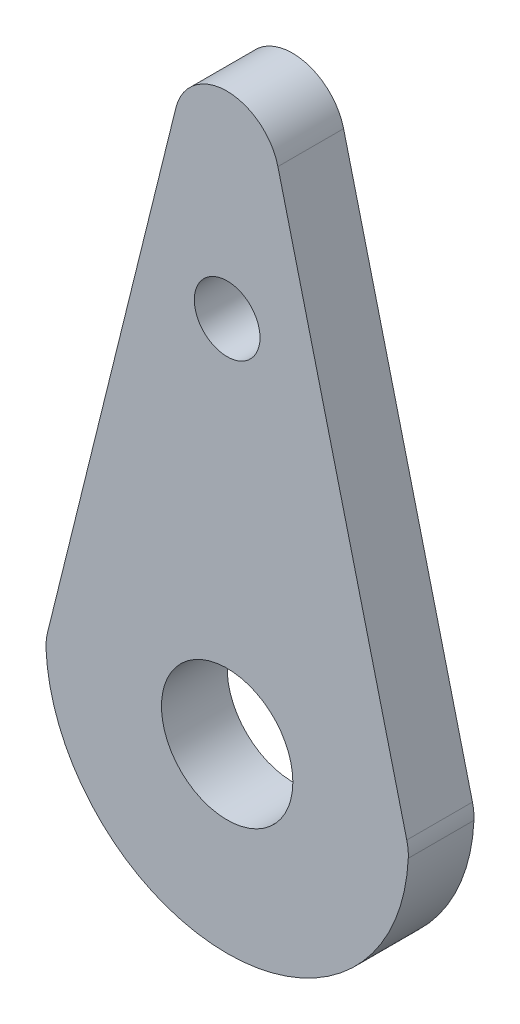
from build123d import *

# Parameters (mm, degrees)
SKETCH1_R                    = 3.175
BOSS_EXTRUDE1_DEPTH          = 3.175
F_1_8_0_125_DIAMETER_HOLE1_D = 3.175


with BuildPart() as part:
    # Sketch1 → Boss-Extrude1 (new body)
    with BuildSketch(Plane.XY):
        with BuildLine():
            Line((-8.682173031, 0.326637814), (-2.477735609, 25.4))
            ThreePointArc((-2.477735609, 25.4), (-0.013242247, 27.329875409), (2.45298258, 25.402213164))
            Line((2.45298258, 25.402213164), (8.681575809, 0.327789055))
            ThreePointArc((8.681575809, 0.327789055), (8.744087205, -0.033833939), (8.753834359, -0.400690665))
            ThreePointArc((8.753834359, -0.400690665), (-0.00074846, -8.762999968), (-8.753902679, -0.399195305))
            ThreePointArc((-8.753902679, -0.399195305), (-8.744226674, -0.033690664), (-8.682173031, 0.326637814))
        make_face()
        Circle(SKETCH1_R, mode=Mode.SUBTRACT)
    extrude(amount=BOSS_EXTRUDE1_DEPTH)

    # 1/8 (0.125) Diameter Hole1 (through all)
    with Locations(Plane.XY.offset(3.175)):
        with Locations((0, 17.804875409)):
            Hole(F_1_8_0_125_DIAMETER_HOLE1_D / 2)


solid = part.part
